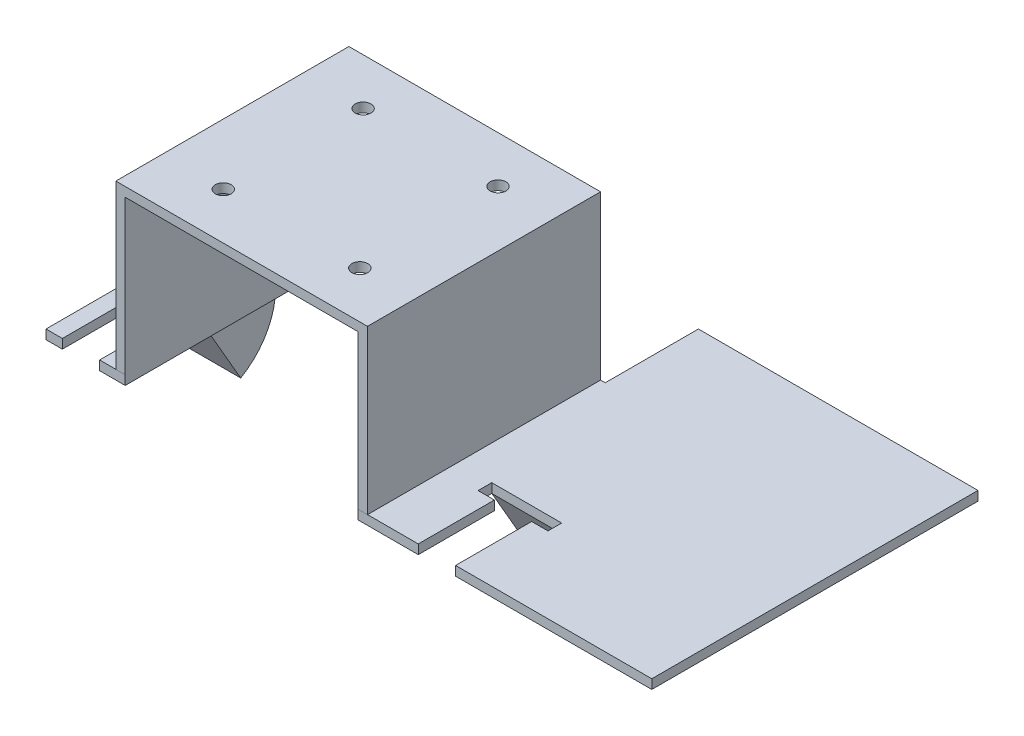
from build123d import *

# Parameters (mm, degrees)
SKETCH2_W                = 130
SKETCH2_H                = 70
BOSS_EXTRUDE1_DEPTH      = 2
SKETCH3_W                = 54
SKETCH3_H                = 70
BOSS_EXTRUDE2_DEPTH      = 35
SKETCH4_W                = 50
SKETCH4_H                = 70
CUT_EXTRUDE2_DEPTH       = 33
CUT_EXTRUDE2_DEPTH_BACK  = 2
SKETCH6_W                = 50
SKETCH6_H                = 2
CUT_EXTRUDE3_DEPTH       = 33
SKETCH7_W                = 70
SKETCH7_H                = 20
CUT_EXTRUDE4_DEPTH       = 40
M3_CLEARANCE_HOLE4_D     = 3.4
M3_CLEARANCE_HOLE4_DEPTH = 3.5
M3_CLEARANCE_HOLE4_TIP   = 1.021463052
SKETCH21_W               = 15
SKETCH21_H               = 15
REVOLVE1_ANGLE           = 60
SKETCH22_W               = 15
SKETCH22_H               = 2.941288486
CUT_EXTRUDE6_DEPTH       = 55
SKETCH23_W               = 8
SKETCH23_H               = 16.328711514
CUT_EXTRUDE7_DEPTH       = 55


with BuildPart() as part:
    # Sketch2 → Boss-Extrude1 (new body)
    with BuildSketch(Plane(origin=(0, 0, 0), x_dir=(1, 0, 0), z_dir=(0, 1, 0))):
        with Locations((-41.699117153, 6.475560132)):
            Rectangle(SKETCH2_W, SKETCH2_H)
    extrude(amount=BOSS_EXTRUDE1_DEPTH)

    # Sketch3 → Boss-Extrude2 (add)
    with BuildSketch(Plane(origin=(0, 2, 0), x_dir=(1, 0, 0), z_dir=(0, 1, 0))):
        with Locations((-64.699117153, 6.461257978)):
            Rectangle(SKETCH3_W, SKETCH3_H)
    extrude(amount=BOSS_EXTRUDE2_DEPTH)

    # Sketch4 → Cut-Extrude2 (cut, two sides)
    with BuildSketch(Plane(origin=(0, 2, 0), x_dir=(1, 0, 0), z_dir=(0, 1, 0))) as cut_extrude2_sk:
        with Locations((-64.699117153, 6.461257978)):
            Rectangle(SKETCH4_W, SKETCH4_H)
    extrude(amount=CUT_EXTRUDE2_DEPTH, mode=Mode.SUBTRACT)
    extrude(cut_extrude2_sk.sketch, amount=-CUT_EXTRUDE2_DEPTH_BACK, mode=Mode.SUBTRACT)

    # Sketch6 → Cut-Extrude3 (cut)
    with BuildSketch(Plane(origin=(0, 0, -41.475560132), x_dir=(-1, 0, 0), z_dir=(0, 0, -1))):
        with Locations((64.699117153, 1)):
            Rectangle(SKETCH6_W, SKETCH6_H)
    extrude(amount=-CUT_EXTRUDE3_DEPTH, mode=Mode.SUBTRACT)

    # Sketch7 → Cut-Extrude4 (cut)
    with BuildSketch(Plane.XZ):
        with Locations((-71.699117153, -31.475560132)):
            Rectangle(SKETCH7_W, SKETCH7_H)
    extrude(amount=-CUT_EXTRUDE4_DEPTH, mode=Mode.SUBTRACT)

    # M3 Clearance Hole4
    with Locations(Plane(origin=(0, 35, 0), x_dir=(-1, 0, 0), z_dir=(0, -1, 0))):
        with Locations((49.339561588, -18.538742022), (49.699117153, 11.475560132), (78.653715997, -18.538742022), (78.653715997, 11.475560132)):
            Hole(M3_CLEARANCE_HOLE4_D / 2, depth=M3_CLEARANCE_HOLE4_DEPTH)
            with Locations((0, 0, -(M3_CLEARANCE_HOLE4_DEPTH + M3_CLEARANCE_HOLE4_TIP / 2))):  # 118° drill point
                Cone(0, M3_CLEARANCE_HOLE4_D / 2, M3_CLEARANCE_HOLE4_TIP, mode=Mode.SUBTRACT)

    # Sketch21 → Revolve1 (revolve)
    with BuildSketch(Plane.XZ):
        with Locations((-22.811286853, 1.754439868)):
            Rectangle(SKETCH21_W, SKETCH21_H)
    revolve1 = revolve(axis=Axis((-30.311286853, 0, 9.254439868), (-1, 0, 0)), revolution_arc=REVOLVE1_ANGLE)

    # Sketch22 → Cut-Extrude6 (cut)
    with BuildSketch(Plane.XZ):
        with Locations((-22.811286853, 10.725084111)):
            Rectangle(SKETCH22_W, SKETCH22_H)
    cut_extrude6 = extrude(amount=-CUT_EXTRUDE6_DEPTH, mode=Mode.SUBTRACT)

    # Sketch23 → Cut-Extrude7 (cut)
    with BuildSketch(Plane.XZ):
        with Locations((-22.811286853, 20.360084111)):
            Rectangle(SKETCH23_W, SKETCH23_H)
    cut_extrude7 = extrude(amount=-CUT_EXTRUDE7_DEPTH, mode=Mode.SUBTRACT)

    # Mirror1: Revolve1 across plane
    add(revolve1.mirror(Plane.ZY.offset(60.999117153)))

    # Mirror2: Cut-Extrude6, Cut-Extrude7 across plane
    add(cut_extrude6.mirror(Plane.ZY.offset(60.999117153)), mode=Mode.SUBTRACT)
    add(cut_extrude7.mirror(Plane.ZY.offset(60.999117153)), mode=Mode.SUBTRACT)


solid = part.part
